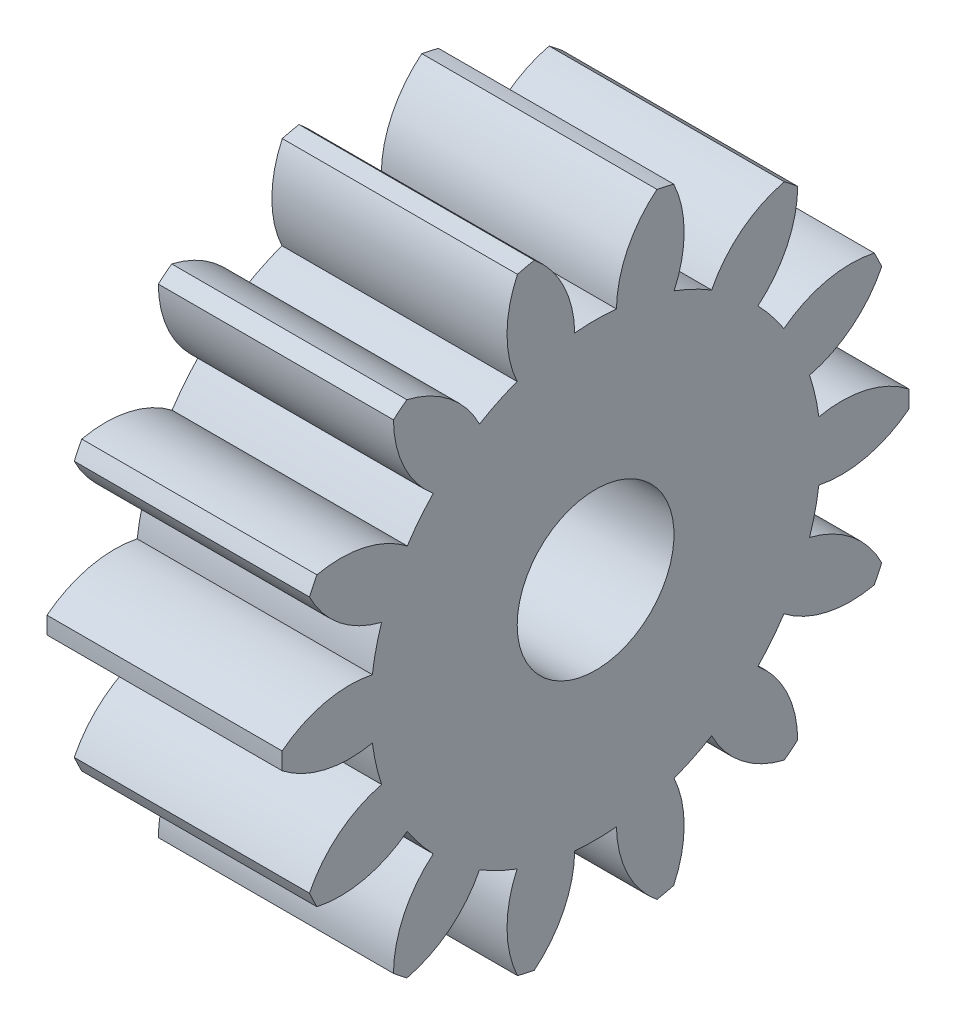
from build123d import *

# Parameters (mm, degrees)
BASPROSKE_W     = 1.5
BASPROSKE_H     = 2
TOOTHCUT_DEPTH  = 4.201562119
TEETHCUTS_COUNT = 14
TEETHCUTS_ANGLE = 334.285714286
BORSKE_R        = 0.5
BORE_DEPTH      = 50.0000508


with BuildPart() as part:
    # BasProSke → Base-Revolve (revolve)
    with BuildSketch(Plane(origin=(0, 0, 0), x_dir=(1, 0, 0), z_dir=(0, 1, 0)), mode=Mode.PRIVATE) as base_revolve_sk:
        with Locations((0.75, 1)):
            Rectangle(BASPROSKE_W, BASPROSKE_H)
    revolve(base_revolve_sk.sketch.rotate(Axis((-10, 0, 0), (1, 0, 0)), 180), axis=Axis((-10, 0, 0), (1, 0, 0)))

    # TooCutSke → ToothCut (cut, through all)
    with BuildSketch(Plane(origin=(0, 0, 0), x_dir=(0, 0, -1), z_dir=(1, 0, 0))):
        with BuildLine():
            ThreePointArc((0.132926628, 1.43033659), (0, 1.4365), (-0.132926628, 1.43033659))
            ThreePointArc((-0.132926628, 1.43033659), (-0.210971396, 1.739395683), (-0.417964864, 1.981804867))
            ThreePointArc((-0.417964864, 1.981804867), (0, 2.0254), (0.417964864, 1.981804867))
            ThreePointArc((0.417964864, 1.981804867), (0.210971396, 1.739395683), (0.132926628, 1.43033659))
        make_face()
    toothcut = extrude(amount=TOOTHCUT_DEPTH, mode=Mode.SUBTRACT)

    # TeethCuts: ToothCut ×14 about axis
    teethcuts_axis = Axis((-10, 0, 0), (1, 0, 0))
    for i in range(1, TEETHCUTS_COUNT):
        add(toothcut.rotate(teethcuts_axis, i * TEETHCUTS_ANGLE / (TEETHCUTS_COUNT - 1)), mode=Mode.SUBTRACT)

    # BorSke → Bore (cut, symmetric)
    with BuildSketch(Plane(origin=(0, 0, 0), x_dir=(0, 0, -1), z_dir=(1, 0, 0))):
        with Locations(Location((0, 0, 0), (0, 0, 180))):
            Circle(BORSKE_R)
    extrude(amount=BORE_DEPTH, both=True, mode=Mode.SUBTRACT)


solid = part.part
